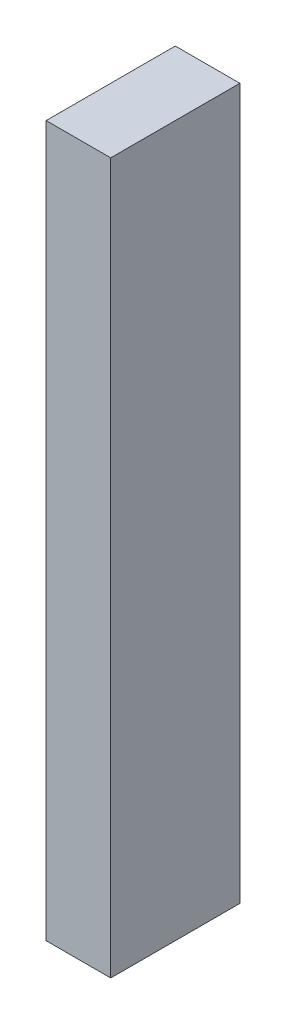
from build123d import *

# Parameters (mm, degrees)
SKETCH1_W           = 25.4
SKETCH1_H           = 50.8
BOSS_EXTRUDE1_DEPTH = 279.4


with BuildPart() as part:
    # Sketch1 → Boss-Extrude1 (new body)
    with BuildSketch(Plane(origin=(0, 0, 0), x_dir=(1, 0, 0), z_dir=(0, 1, 0))):
        with Locations((12.7, 25.4)):
            Rectangle(SKETCH1_W, SKETCH1_H)
    extrude(amount=BOSS_EXTRUDE1_DEPTH)


solid = part.part
